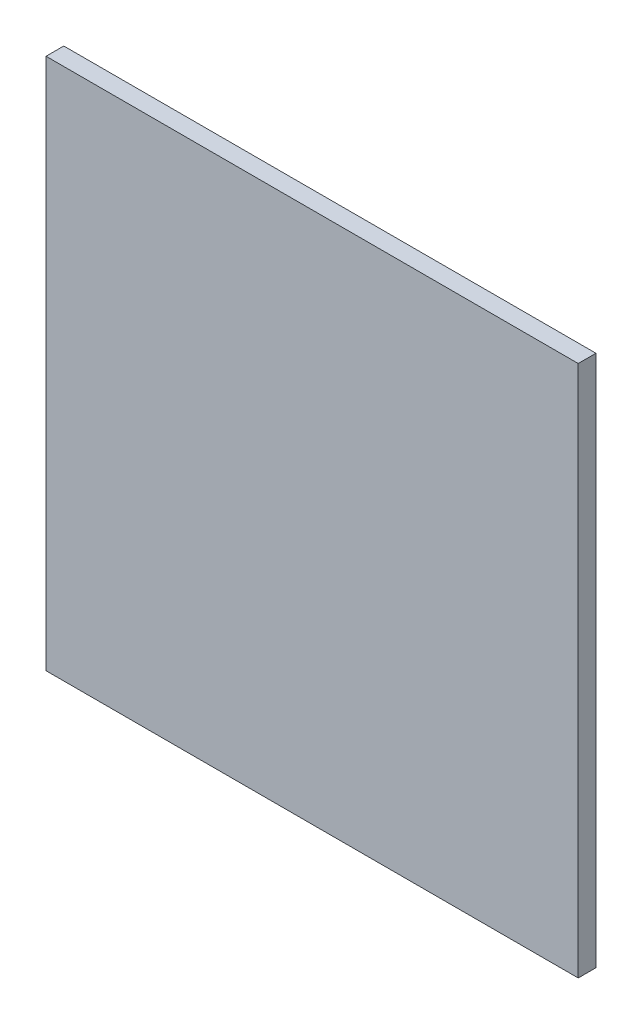
from build123d import *

# Parameters (mm, degrees)
ESQUISSE1_W        = 300
ESQUISSE1_H        = 300
BOSS_EXTRU_1_DEPTH = 10


with BuildPart() as part:
    # Esquisse1 → Boss.-Extru.1 (new body)
    with BuildSketch(Plane.XY):
        with Locations((150, 150)):
            Rectangle(ESQUISSE1_W, ESQUISSE1_H)
    extrude(amount=BOSS_EXTRU_1_DEPTH)


solid = part.part
